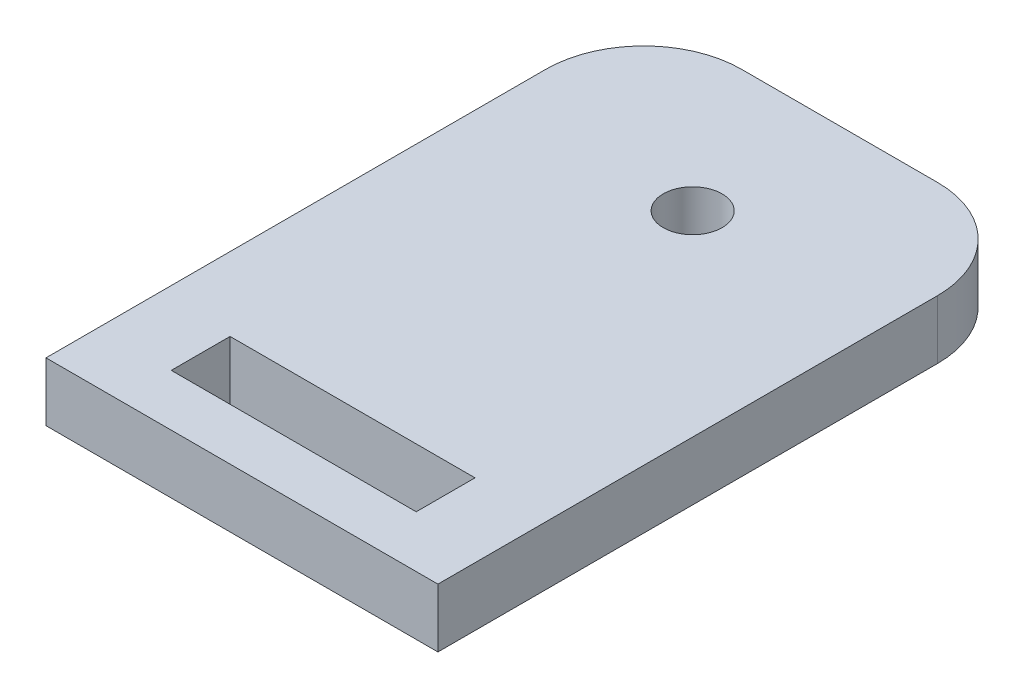
from build123d import *

# Parameters (mm, degrees)
SKETCH1_R           = 3
SKETCH1_W           = 25
SKETCH1_H           = 6
BOSS_EXTRUDE1_DEPTH = 6


with BuildPart() as part:
    # Sketch1 → Boss-Extrude1 (new body)
    with BuildSketch(Plane(origin=(0, 0, 0), x_dir=(1, 0, 0), z_dir=(0, 1, 0))):
        with BuildLine():
            Line((-18.981997388, -27.5), (21.018002612, -27.5))
            Line((21.018002612, -27.5), (21.018002612, 23.5))
            ThreePointArc((21.018002612, 23.5), (18.089070424, 30.571067812), (11.018002612, 33.5))
            Line((11.018002612, 33.5), (-8.981997388, 33.5))
            ThreePointArc((-8.981997388, 33.5), (-16.053065199, 30.571067812), (-18.981997388, 23.5))
            Line((-18.981997388, 23.5), (-18.981997388, -27.5))
        make_face()
        with Locations((1.018002612, 18.5)):
            Circle(SKETCH1_R, mode=Mode.SUBTRACT)
        with Locations((1.018002612, -19.214324507)):
            Rectangle(SKETCH1_W, SKETCH1_H, mode=Mode.SUBTRACT)
    extrude(amount=BOSS_EXTRUDE1_DEPTH)


solid = part.part
